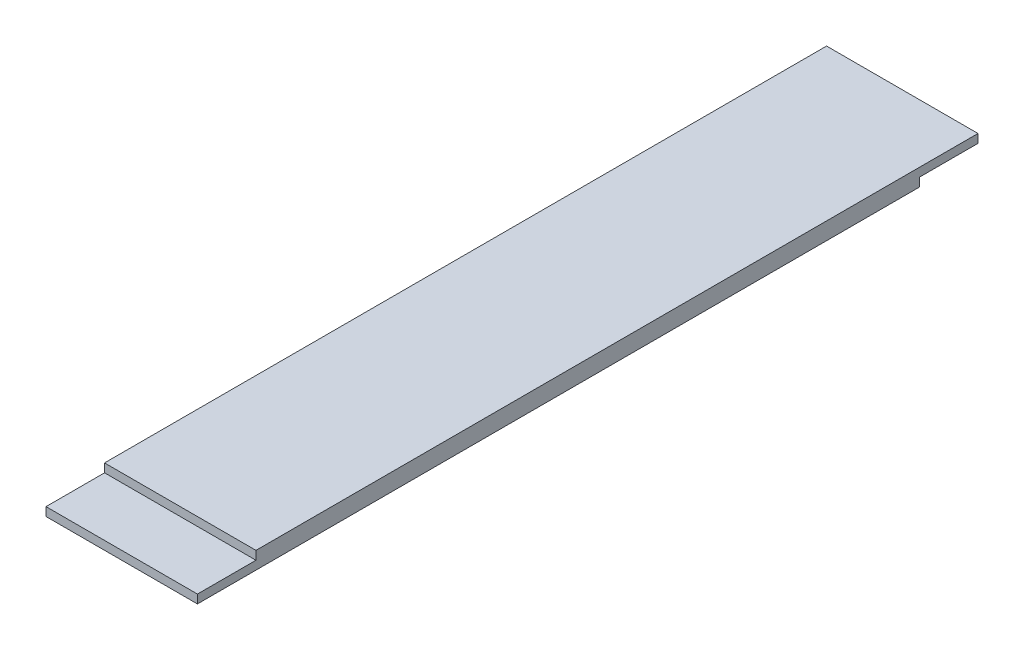
from build123d import *

# Parameters (mm, degrees)
SKETCH_1_W          = 38.8
SKETCH_1_H          = 200
EXTRUDE_1_DEPTH     = 4.4
SKETCH_3_W          = 38.8
SKETCH_3_H          = 15
CUT_EXTRUDE_1_DEPTH = 2.2
SKETCH_4_W          = 38.8
SKETCH_4_H          = 15
CUT_EXTRUDE_2_DEPTH = 2.2


with BuildPart() as part:
    # 草圖1 → 填料-伸長1 (new body)
    with BuildSketch(Plane(origin=(0, 0, 0), x_dir=(1, 0, 0), z_dir=(0, 1, 0))):
        Rectangle(SKETCH_1_W, SKETCH_1_H)
    extrude(amount=EXTRUDE_1_DEPTH)

    # 草圖3 → 除料-伸長1 (cut)
    with BuildSketch(Plane(origin=(0, 4.4, 0), x_dir=(1, 0, 0), z_dir=(0, 1, 0))):
        with Locations((0, -92.5)):
            Rectangle(SKETCH_3_W, SKETCH_3_H)
    extrude(amount=-CUT_EXTRUDE_1_DEPTH, mode=Mode.SUBTRACT)

    # 草圖4 → 除料-伸長2 (cut)
    with BuildSketch(Plane.XZ):
        with Locations((0, -92.5)):
            Rectangle(SKETCH_4_W, SKETCH_4_H)
    extrude(amount=-CUT_EXTRUDE_2_DEPTH, mode=Mode.SUBTRACT)


solid = part.part
